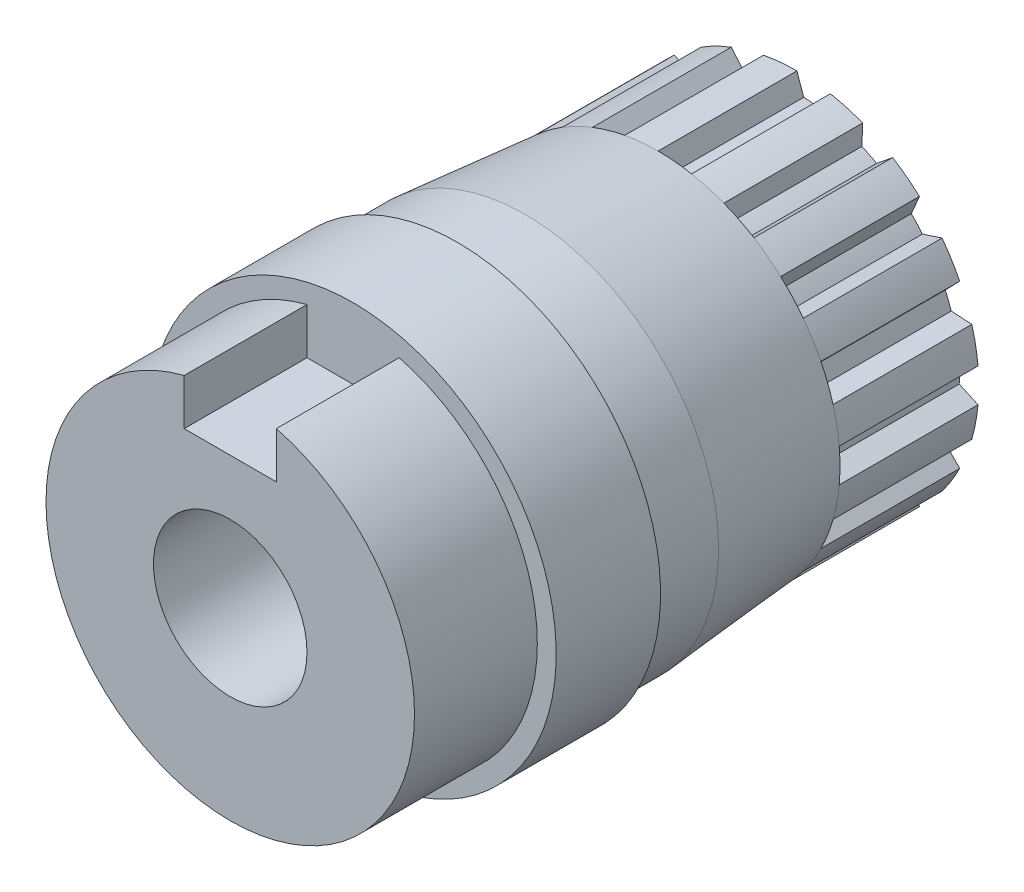
from build123d import *

# Parameters (mm, degrees)
BOSS_EXTRUDE1_DEPTH = 27.94
CIRPATTERN1_COUNT   = 17
SKETCH5_R           = 7.9375
SKETCH5_W           = 9.525
SKETCH5_H           = 11.576298251
CUT_EXTRUDE1_DEPTH  = 12.7
SKETCH5_2_R         = 7.9375
CUT_EXTRUDE2_DEPTH  = 70


with BuildPart() as part:
    # Sketch2 → Revolve1 (revolve)
    with BuildSketch(Plane(origin=(0, 0, 0), x_dir=(1, 0, 0), z_dir=(0, 1, 0))):
        Polygon((0, -14.35), (0, -58.593750066), (-19.05, -58.593750066), (-19.05, -45.893750066), (-21, -45.893750066), (-21, -35.1), (-20, -35.1), (-20, -28.1), (-18.8, -14.35), align=None)
    revolve(axis=Axis((0, 0, 14.35), (0, 0, 1)))

    # Sketch4 → Boss-Extrude1 (add)
    with BuildSketch(Plane.XY):
        with BuildLine():
            Line((-3.454490935, 18.479894274), (-3.774098097, 16.37058898))
            ThreePointArc((-3.774098097, 16.37058898), (-4.597538233, 16.158670805), (-5.40920169, 15.905361897))
            Line((-5.40920169, 15.905361897), (-6.791343324, 17.530477913))
            Line((-6.791343324, 17.530477913), (0, 0))
            Line((0, 0), (0, 18.8))
            ThreePointArc((0, 18.8), (-1.734645158, 18.719802514), (-3.454490935, 18.479894274))
        make_face()
    boss_extrude1 = extrude(amount=BOSS_EXTRUDE1_DEPTH)

    # CirPattern1: Boss-Extrude1 ×17 about axis
    cirpattern1_axis = Axis((0, 0, 27.94), (0, 0, -1))
    for i in range(1, CIRPATTERN1_COUNT):
        add(boss_extrude1.rotate(cirpattern1_axis, i * 360 / CIRPATTERN1_COUNT))

    # Sketch5 → Cut-Extrude1 (cut)
    with BuildSketch(Plane.XY.offset(58.593750066)):
        Circle(SKETCH5_R)
        with Locations((0, 19.470732312)):
            Rectangle(SKETCH5_W, SKETCH5_H)
    extrude(amount=-CUT_EXTRUDE1_DEPTH, mode=Mode.SUBTRACT)

    # Sketch5_2 → Cut-Extrude2 (cut)
    with BuildSketch(Plane.XY.offset(58.593750066)):
        Circle(SKETCH5_2_R)
    extrude(amount=-CUT_EXTRUDE2_DEPTH, mode=Mode.SUBTRACT)


solid = part.part
